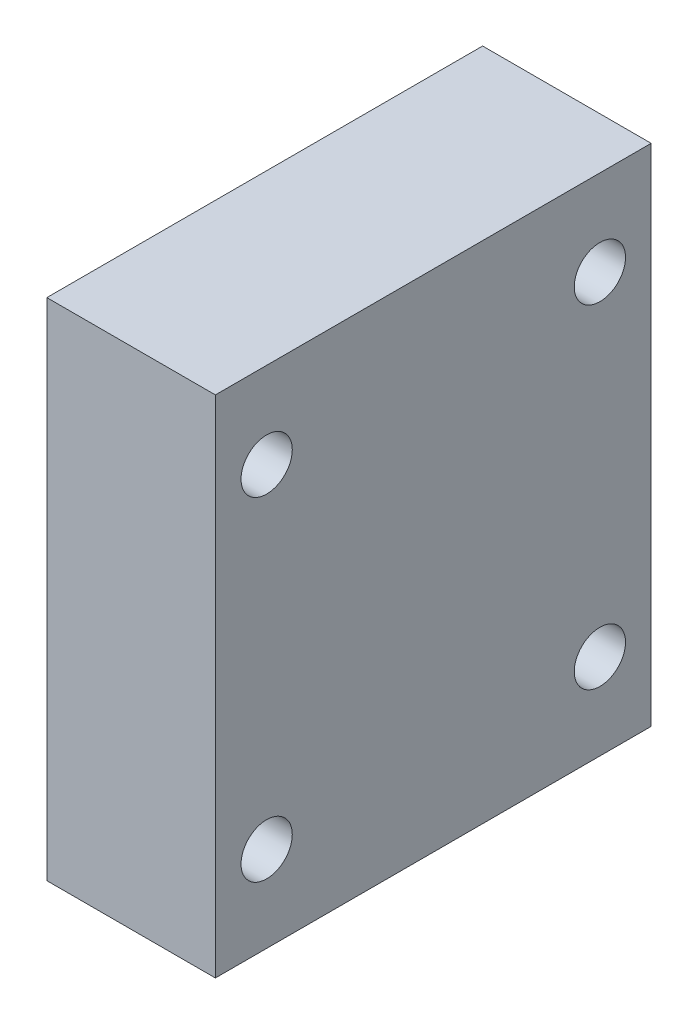
from build123d import *

# Parameters (mm, degrees)
SKETCH_1_W      = 34
SKETCH_1_H      = 39.4
SKETCH_1_R      = 2
EXTRUDE_1_DEPTH = 13.15


with BuildPart() as part:
    # Эскиз1 → Бобышка-Вытянуть1 (new body)
    with BuildSketch(Plane(origin=(0, 0, 0), x_dir=(0, 0, -1), z_dir=(1, 0, 0))):
        Rectangle(SKETCH_1_W, SKETCH_1_H)
        with Locations((-13, 13)):
            Circle(SKETCH_1_R, mode=Mode.SUBTRACT)
        with Locations((13, 13)):
            Circle(SKETCH_1_R, mode=Mode.SUBTRACT)
        with Locations((13, -13)):
            Circle(SKETCH_1_R, mode=Mode.SUBTRACT)
        with Locations((-13, -13)):
            Circle(SKETCH_1_R, mode=Mode.SUBTRACT)
    extrude(amount=EXTRUDE_1_DEPTH)


solid = part.part
